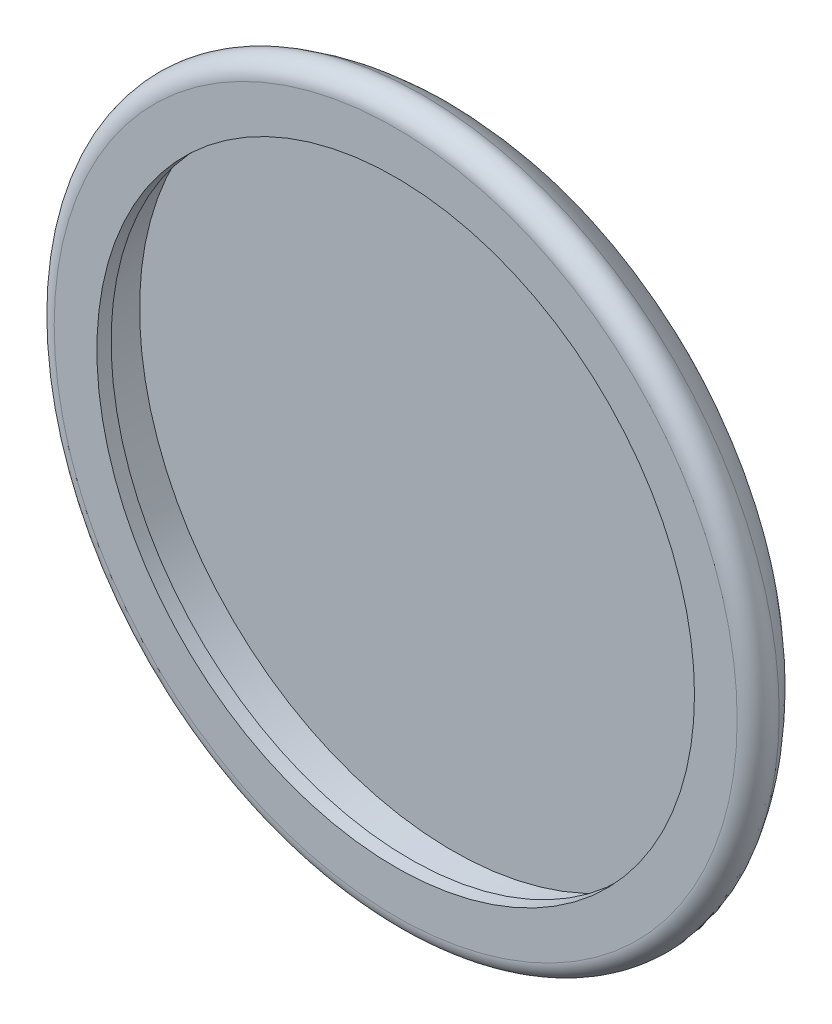
from build123d import *


with BuildPart() as part:
    # Croquis1 → Revolución1 (revolve)
    with BuildSketch(Plane(origin=(0, 0, 0), x_dir=(1, 0, 0), z_dir=(0, 1, 0))):
        with BuildLine():
            Line((0, 6), (18, 6))
            ThreePointArc((18, 6), (22.102949779, 4.89077105), (25.088082902, 1.865284974))
            ThreePointArc((25.088082902, 1.865284974), (25.079723626, 0.620161218), (24, 0))
            Line((24, 0), (21, 0))
            Line((21, 0), (21, 1))
            Line((21, 1), (22, 1))
            Line((22, 1), (22, 4))
            Line((22, 4), (0, 4))
            Line((0, 4), (0, 6))
        make_face()
    revolve(axis=Axis((0, 0, 0), (0, 0, -1)))


solid = part.part
